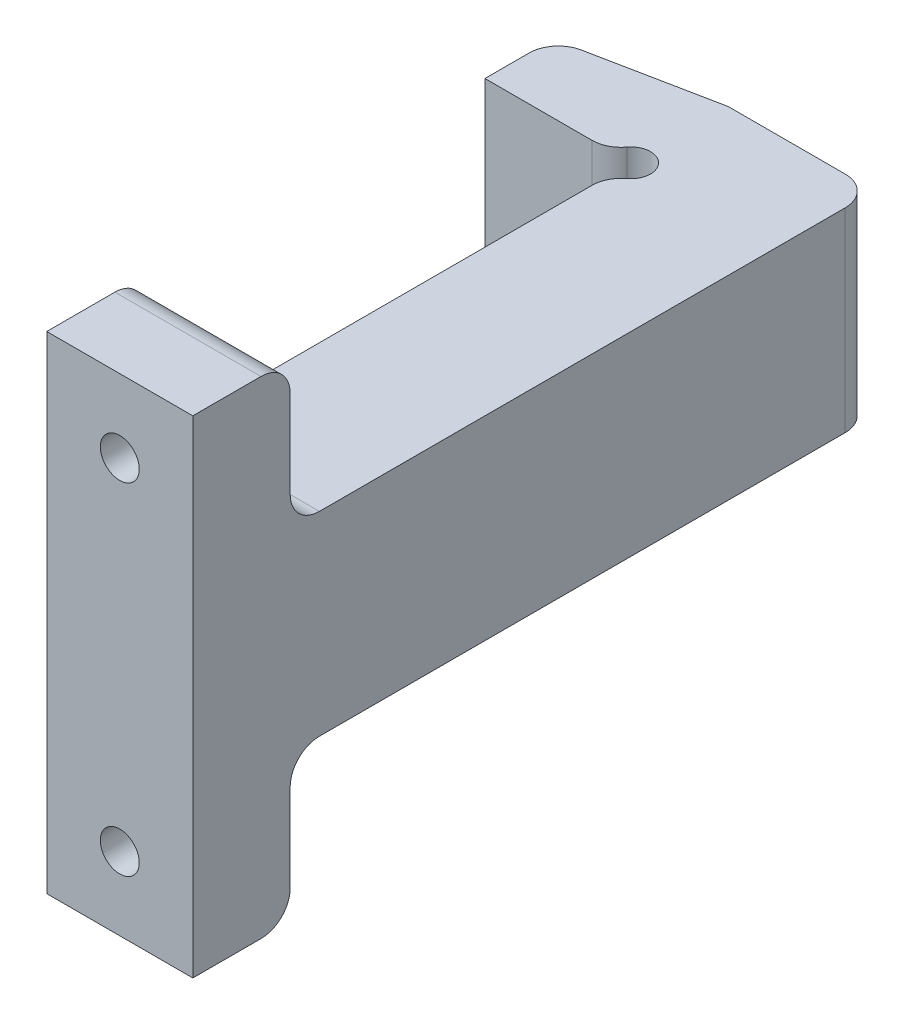
from build123d import *

# Parameters (mm, degrees)
BOSS_EXTRUDE1_DEPTH = 20
SKETCH2_W           = 15
SKETCH2_H           = 15
SKETCH2_R           = 2
BOSS_EXTRUDE2_DEPTH = 10
FILLET1_R           = 3


with BuildPart() as part:
    # Sketch1 → Boss-Extrude1 (new body)
    with BuildSketch(Plane(origin=(0, 0, 0), x_dir=(1, 0, 0), z_dir=(0, 1, 0))):
        with BuildLine():
            Line((0, 0), (-13, 0))
            Line((-13, 0), (-13, 7))
            Line((-13, 7), (2, 10))
            Line((2, 10), (17, 10))
            Line((17, 10), (17, -60))
            Line((17, -60), (2, -60))
            Line((2, -60), (2, -2))
            ThreePointArc((2, -2), (3.414213562, 1.414213562), (0, 0))
        make_face()
    extrude(amount=BOSS_EXTRUDE1_DEPTH)

    # Sketch2 → Boss-Extrude2 (add)
    with BuildSketch(Plane.XY.offset(60)):
        with Locations((9.5, 27.5)):
            Rectangle(SKETCH2_W, SKETCH2_H)
        with Locations((9.5, 27.5)):
            Circle(SKETCH2_R, mode=Mode.SUBTRACT)
        with Locations((9.5, -7.5)):
            Rectangle(SKETCH2_W, SKETCH2_H)
        with Locations((9.5, -7.5)):
            Circle(SKETCH2_R, mode=Mode.SUBTRACT)
    extrude(amount=-BOSS_EXTRUDE2_DEPTH)

    # Fillet1
    fillet1_edges = [part.edges().sort_by_distance(p)[0] for p in [
        (0, 10, 0),
        (-13, 10, -7),
        (2, 10, -10),
        (17, 10, -10),
        (2, 10, 2),
        (9.5, 35, 50),
        (9.5, 20, 50),
        (9.5, 0, 50),
        (9.5, -15, 50),
    ]]
    fillet(fillet1_edges, radius=FILLET1_R)


solid = part.part
